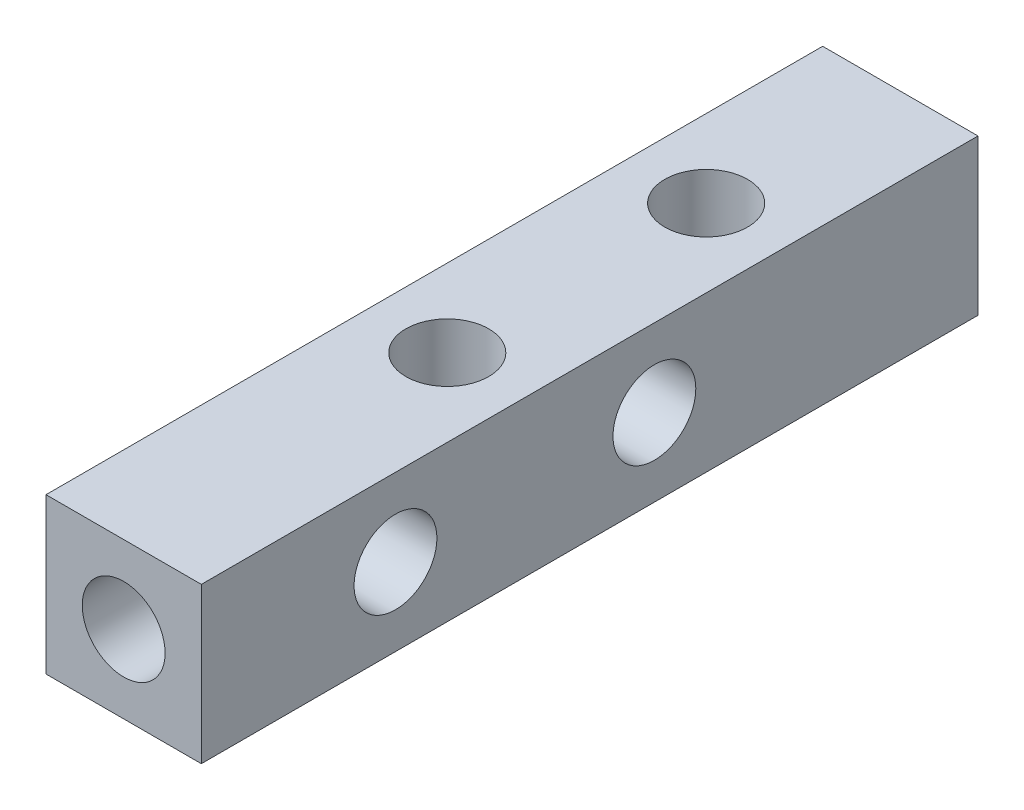
from build123d import *

# Parameters (mm, degrees)
SKETCH_1_W          = 6
SKETCH_1_H          = 6
EXTRUDE_1_DEPTH     = 30
SKETCH_2_R          = 1.6
CUT_EXTRUDE_1_DEPTH = 5
CUT_EXTRUDE_START   = -30
SKETCH_2_2_R        = 1.6
CUT_EXTRUDE_2_DEPTH = 5
SKETCH_3_R          = 1.6
CUT_EXTRUDE_3_DEPTH = 7
SKETCH_4_R          = 1.6
CUT_EXTRUDE_4_DEPTH = 7


with BuildPart() as part:
    # 草图1 → 凸台-拉伸1 (new body)
    with BuildSketch(Plane.XY):
        with Locations((3, 3)):
            Rectangle(SKETCH_1_W, SKETCH_1_H)
    extrude(amount=EXTRUDE_1_DEPTH)

    # 草图2 → 切除-拉伸1 (cut)
    with BuildSketch(Plane.XY.offset(30)):
        with Locations((3, 3)):
            Circle(SKETCH_2_R)
    extrude(amount=-CUT_EXTRUDE_1_DEPTH, mode=Mode.SUBTRACT)

    # 草图2<2> → 切除-拉伸2 (cut)
    with BuildSketch(Plane.XY.offset(30).offset(CUT_EXTRUDE_START)):
        with Locations((3, 3)):
            Circle(SKETCH_2_2_R)
    extrude(amount=CUT_EXTRUDE_2_DEPTH, mode=Mode.SUBTRACT)

    # 草图3 → 切除-拉伸3 (cut)
    with BuildSketch(Plane(origin=(6, 0, 0), x_dir=(0, 0, -1), z_dir=(1, 0, 0))):
        with Locations((-22.5, 3)):
            Circle(SKETCH_3_R)
        with Locations((-12.5, 3)):
            Circle(SKETCH_3_R)
    extrude(amount=-CUT_EXTRUDE_3_DEPTH, mode=Mode.SUBTRACT)

    # 草图4 → 切除-拉伸4 (cut)
    with BuildSketch(Plane(origin=(0, 6, 0), x_dir=(1, 0, 0), z_dir=(0, 1, 0))):
        with Locations((3, -7.5)):
            Circle(SKETCH_4_R)
        with Locations((3, -17.5)):
            Circle(SKETCH_4_R)
    extrude(amount=-CUT_EXTRUDE_4_DEPTH, mode=Mode.SUBTRACT)


solid = part.part
